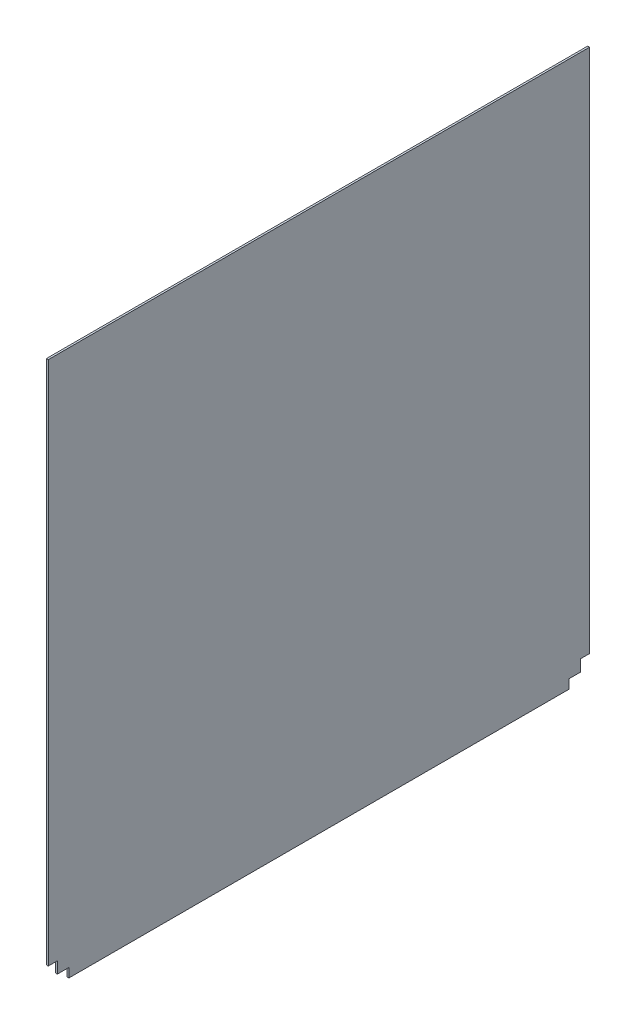
from build123d import *

# Parameters (mm, degrees)
BOSS_EXTRUDE4_DEPTH = 3.175


with BuildPart() as part:
    # Sketch2 → Boss-Extrude4 (new body)
    with BuildSketch(Plane(origin=(0, 0, 0), x_dir=(0, 0, -1), z_dir=(1, 0, 0))):
        Polygon((891.76098, 34.544), (907.00098, 34.544), (907.00098, 914.4), (0, 914.4), (0, 34.544), (15.24, 34.544), (15.24, 15.24), (34.544, 15.24), (34.544, 0), (872.45698, 0), (872.45698, 15.24), (891.76098, 15.24), align=None)
    extrude(amount=BOSS_EXTRUDE4_DEPTH)


solid = part.part
